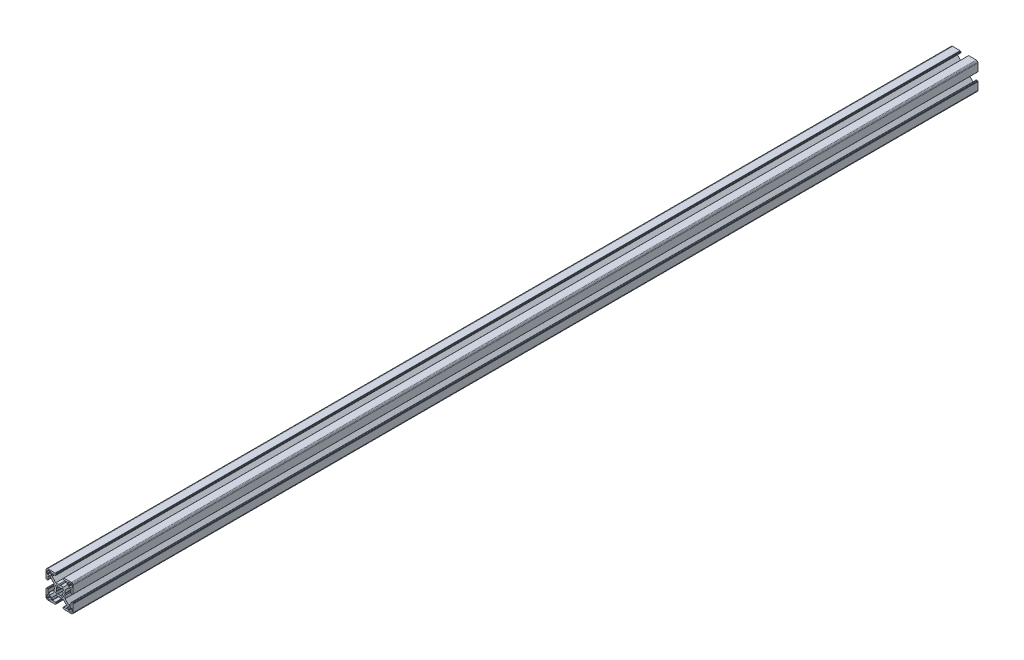
from build123d import *

# Parameters (mm, degrees)
BOSS_EXTRUDE1_DEPTH = 1000


with BuildPart() as part:
    # Sketch1 → Boss-Extrude1 (new body)
    with BuildSketch(Plane.XY):
        Polygon((28.34729664, 29.969613999), (28.000000864, 29.999999329), (19.750000909, 29.999999329), (19.715268165, 29.996961355), (19.681595266, 29.987938702), (19.649999216, 29.973205179), (19.621443003, 29.953207821), (19.596790895, 29.928557575), (19.576793537, 29.899999499), (19.562061876, 29.868405312), (19.55303736, 29.834728688), (19.549999386, 29.799999669), (19.549999386, 29.699999839), (19.546961412, 29.665268958), (19.537936896, 29.631596059), (19.523203373, 29.599998146), (19.503207877, 29.571441934), (19.478557631, 29.546789825), (19.449999556, 29.526794329), (19.418403506, 29.512060806), (19.384728745, 29.503038153), (19.349999726, 29.500000179), (19.249999896, 29.500000179), (19.215267517, 29.496958527), (19.181592755, 29.487935874), (19.149996706, 29.47320235), (19.12143863, 29.453206855), (19.096788384, 29.428554746), (19.076791026, 29.399996671), (19.062057503, 29.368402484), (19.05303485, 29.334725859), (19.049996876, 29.299998703), (19.049996876, 28.39999837), (19.059110798, 28.29580945), (19.08618062, 28.194785165), (19.13038119, 28.099997016), (19.190369539, 28.014324653), (19.264324002, 27.94037019), (19.349996366, 27.88038184), (19.444784515, 27.836181271), (19.545806937, 27.809111449), (19.650010894, 27.799984574), (23.050010706, 27.799984574), (23.084741588, 27.7969466), (23.118414487, 27.787923946), (23.150012399, 27.773190423), (23.178568612, 27.753193065), (23.203220721, 27.728542819), (23.223218079, 27.699984744), (23.237949739, 27.668386831), (23.246974255, 27.634713932), (23.25001142, 27.59998608), (23.25001142, 25.049987618), (19.204474482, 20.999982084), (15.900007876, 20.999982084), (15.000008474, 20.48483404), (14.10000814, 20.999982084), (10.795543398, 20.999982084), (7.997342887, 23.801274731), (6.750011387, 25.049984589), (6.750011387, 27.599983051), (6.753049362, 27.634713932), (6.762072946, 27.668386831), (6.776805538, 27.699984744), (6.796801965, 27.728542819), (6.821454073, 27.753193065), (6.850011218, 27.773190423), (6.881607267, 27.787923946), (6.915282029, 27.7969466), (6.950011048, 27.799984574), (10.350011791, 27.799984574), (10.45420071, 27.809098497), (10.555223133, 27.836168318), (10.650011282, 27.880368888), (10.735683645, 27.940357238), (10.809638108, 28.014311701), (10.869626458, 28.099984064), (10.913827027, 28.194772213), (10.940895918, 28.295796498), (10.950010772, 28.399985417), (10.950010772, 29.299985751), (10.946974575, 29.334739239), (10.93795065, 29.368415522), (10.923215933, 29.400009153), (10.903218427, 29.428566473), (10.878566319, 29.45321765), (10.849999264, 29.473204166), (10.818403214, 29.487937689), (10.784728453, 29.496960342), (10.749999434, 29.500000179), (10.649999604, 29.500000179), (10.615270585, 29.503038153), (10.581595823, 29.512060806), (10.549999774, 29.526794329), (10.521441698, 29.546789825), (10.496791452, 29.571441934), (10.476795025, 29.599998146), (10.462061502, 29.631596059), (10.453037918, 29.665268958), (10.449999943, 29.699999839), (10.449999943, 29.799999669), (10.446961969, 29.834728688), (10.437938385, 29.868405312), (10.423205793, 29.899999499), (10.403208435, 29.928557575), (10.378557257, 29.953207821), (10.350000113, 29.973205179), (10.318404064, 29.987938702), (10.284729302, 29.996961355), (10.250000283, 29.999999329), (1.999999397, 29.999999329), (1.652702689, 29.969613999), (1.315958682, 29.879383743), (0.999999233, 29.732050374), (0.714424066, 29.532089829), (0.467910431, 29.285576195), (0.267948955, 28.999999166), (0.120614655, 28.684040532), (0.030384399, 28.34729664), (0, 28.000000864), (0, 19.750000909), (0.003037974, 19.715268165), (0.012061559, 19.681595266), (0.026795082, 19.649999216), (0.046790577, 19.621441141), (0.071442686, 19.596789032), (0.09999983, 19.576793537), (0.13159588, 19.562060013), (0.165270641, 19.55303736), (0.19999966, 19.549999386), (0.299999461, 19.549999386), (0.334728509, 19.546959549), (0.368403242, 19.537936896), (0.399999321, 19.523203373), (0.428556465, 19.503207877), (0.453208573, 19.478555769), (0.473204069, 19.449997693), (0.487937592, 19.418403506), (0.496961176, 19.384728745), (0.499999151, 19.349999726), (0.499999151, 19.249998033), (0.503038056, 19.215269014), (0.512060709, 19.181594253), (0.526794232, 19.150000066), (0.546790194, 19.121441524), (0.571441837, 19.096789882), (0.60000029, 19.076794925), (0.631595686, 19.062061999), (0.665270619, 19.053039982), (0.700000626, 19.050000801), (1.60000096, 19.050000801), (1.704189879, 19.059116587), (1.805213233, 19.086186409), (1.90000045, 19.130385115), (1.985673745, 19.190375328), (2.059627277, 19.264327928), (2.119616325, 19.350002154), (2.163816196, 19.444788441), (2.190886018, 19.545812726), (2.200000872, 19.650001645), (2.200000872, 23.050001457), (2.203039777, 23.084732338), (2.212062431, 23.118405237), (2.226795954, 23.15000315), (2.246792381, 23.178559362), (2.271443558, 23.203211471), (2.300000702, 23.223206967), (2.331596752, 23.23794049), (2.365271513, 23.246965006), (2.400001464, 23.250001117), (4.950000857, 23.250001117), (7.997332093, 20.202670812), (8.995535423, 19.204467788), (8.995535423, 15.900001182), (9.515148227, 15.00000178), (8.995535423, 14.100002378), (8.995535423, 10.795536704), (4.950000857, 6.750002138), (2.400001464, 6.750002138), (2.365271513, 6.753040112), (2.331596752, 6.762063697), (2.300000702, 6.77679722), (2.271443558, 6.796793647), (2.246792381, 6.821444824), (2.226795954, 6.850001968), (2.212062431, 6.881598018), (2.203039777, 6.915272779), (2.200000872, 6.950002729), (2.200000872, 10.350002542), (2.190896812, 10.454174265), (2.16382699, 10.555197618), (2.119627119, 10.649984836), (2.059638071, 10.735658131), (1.985684539, 10.809611663), (1.900011244, 10.869600944), (1.805224027, 10.913800582), (1.704200673, 10.940870404), (1.600011754, 10.949986189), (0.70001142, 10.949986189), (0.665281355, 10.946948596), (0.631606253, 10.937926283), (0.600010578, 10.923193954), (0.571451747, 10.903199537), (0.546799638, 10.87854836), (0.526794232, 10.850000195), (0.512060709, 10.818404146), (0.503038056, 10.784730315), (0.499999151, 10.750000365), (0.499999151, 10.650000535), (0.496961176, 10.615270585), (0.487937592, 10.581596754), (0.473204069, 10.550000705), (0.453208573, 10.521443561), (0.428556465, 10.496791452), (0.399999321, 10.476795956), (0.368403242, 10.462062433), (0.334728509, 10.453038849), (0.299999461, 10.449999943), (0.19999966, 10.449999943), (0.165270641, 10.446961969), (0.13159588, 10.437939316), (0.09999983, 10.423205793), (0.071442686, 10.403209366), (0.046790577, 10.378558189), (0.026795082, 10.350000113), (0.012061559, 10.318404064), (0.003037974, 10.284729302), (0, 10.250000283), (0, 1.999999397), (0.030384399, 1.652702689), (0.120614655, 1.315958682), (0.267948955, 0.999999233), (0.467910431, 0.714424066), (0.714424066, 0.467910431), (0.999999233, 0.267948955), (1.315958682, 0.120614655), (1.652702689, 0.030384399), (1.999999397, 0), (10.250000283, 0), (10.284729302, 0.003037974), (10.318404064, 0.012061559), (10.350000113, 0.026795082), (10.378557257, 0.046790577), (10.403208435, 0.071442686), (10.423205793, 0.09999983), (10.437938385, 0.13159588), (10.446961969, 0.165270641), (10.449999943, 0.19999966), (10.449999943, 0.300000422), (10.453037918, 0.334729441), (10.462061502, 0.368404202), (10.476795025, 0.400000252), (10.496791452, 0.428557396), (10.521441698, 0.453208573), (10.549999774, 0.473205), (10.581595823, 0.487938523), (10.615270585, 0.496961176), (10.649999604, 0.500000082), (10.749999434, 0.500000082), (10.784728453, 0.503038056), (10.818403214, 0.512060709), (10.849999264, 0.526794232), (10.878547894, 0.546800104), (10.903198606, 0.571451747), (10.923194493, 0.6000102), (10.93792742, 0.631606528), (10.946949437, 0.66528146), (10.950010772, 0.699984975), (10.950010772, 1.599985308), (10.940895918, 1.704174228), (10.913827027, 1.805197581), (10.869626458, 1.89998573), (10.809638108, 1.985658094), (10.735683645, 2.059612557), (10.650011282, 2.119600674), (10.555223133, 2.163801476), (10.45420071, 2.190870367), (10.350011791, 2.199985221), (6.950011048, 2.199985221), (6.915282029, 2.203024126), (6.881607267, 2.212046779), (6.850011218, 2.226780302), (6.821454073, 2.246776729), (6.796801965, 2.271427907), (6.776805538, 2.299985982), (6.762072946, 2.331582032), (6.753049362, 2.365256793), (6.750011387, 2.399985812), (6.750011387, 4.949985206), (9.787457566, 7.990785077), (10.795545277, 8.999985833), (14.100010019, 8.999985833), (15.000010353, 9.515133877), (15.900009756, 8.999985833), (19.204476361, 8.999985833), (20.21256413, 7.990786065), (23.25001142, 4.949988235), (23.25001142, 2.399988841), (23.246974255, 2.365256793), (23.237949739, 2.331582032), (23.223218079, 2.299985982), (23.203220721, 2.271427907), (23.178568612, 2.246776729), (23.150012399, 2.226780302), (23.118414487, 2.212046779), (23.084741588, 2.203024126), (23.050010706, 2.199985221), (19.650010894, 2.199985221), (19.545806937, 2.190883319), (19.444784515, 2.163814428), (19.349996366, 2.119613626), (19.264324002, 2.059625509), (19.190369539, 1.985671046), (19.13038119, 1.899998682), (19.08618062, 1.805210533), (19.059110798, 1.70418718), (19.049996876, 1.599998261), (19.049996876, 0.699997927), (19.053035506, 0.665268966), (19.062058795, 0.631594374), (19.076792915, 0.599998603), (19.096790813, 0.571440905), (19.121441524, 0.546790194), (19.149999978, 0.526794306), (19.181596306, 0.51206138), (19.215271238, 0.503039363), (19.249999896, 0.500000082), (19.349999726, 0.500000082), (19.384728745, 0.496961176), (19.418403506, 0.487938523), (19.449999556, 0.473205), (19.478557631, 0.453208573), (19.503207877, 0.428557396), (19.523203373, 0.400000252), (19.537936896, 0.368404202), (19.546961412, 0.334729441), (19.549999386, 0.300000422), (19.549999386, 0.19999966), (19.55303736, 0.165270641), (19.562061876, 0.13159588), (19.576793537, 0.09999983), (19.596789964, 0.071441755), (19.621442072, 0.046789646), (19.649998285, 0.02679415), (19.681594335, 0.012060627), (19.715267234, 0.003037043), (19.750000909, 0), (28.000000864, 0), (28.34729664, 0.030384399), (28.684040532, 0.120614655), (28.999999166, 0.267948955), (29.285576195, 0.467910431), (29.532089829, 0.714424066), (29.732050374, 0.999999233), (29.879383743, 1.315958682), (29.969613999, 1.652702689), (29.999999329, 1.999999397), (29.999999329, 10.250000283), (29.996974806, 10.284715361), (29.987951516, 10.318389952), (29.973217396, 10.349985723), (29.953219499, 10.378543421), (29.928568787, 10.403194133), (29.899999499, 10.423205793), (29.868405312, 10.437939316), (29.834728688, 10.446961969), (29.799999669, 10.449999943), (29.699999839, 10.449999943), (29.664909937, 10.453400043), (29.631233313, 10.462423628), (29.599637263, 10.477157151), (29.57108105, 10.497152646), (29.546427079, 10.521804755), (29.526433446, 10.550361899), (29.511699923, 10.581957949), (29.502675407, 10.615631779), (29.499637433, 10.650361729), (29.499637433, 10.750361559), (29.49697202, 10.784715548), (29.487949367, 10.818389378), (29.473215844, 10.849985428), (29.453220348, 10.878542572), (29.428568239, 10.90319468), (29.400010164, 10.923190176), (29.368415977, 10.937923699), (29.334741215, 10.946947284), (29.300012197, 10.949986189), (28.400011863, 10.949986189), (28.29581215, 10.9408876), (28.194787865, 10.913817778), (28.099999716, 10.86961814), (28.014327352, 10.809628859), (27.940374752, 10.735675327), (27.880384539, 10.650002032), (27.836185833, 10.555214814), (27.809114148, 10.454191461), (27.800000225, 10.350002542), (27.800000225, 6.950002729), (27.796962251, 6.915272779), (27.787939598, 6.881598018), (27.773206075, 6.850001968), (27.753208716, 6.821444824), (27.728558471, 6.796793647), (27.700000395, 6.77679722), (27.668404345, 6.762063697), (27.634729584, 6.753040112), (27.599998702, 6.750002138), (25.05000024, 6.750002138), (23.809199132, 7.99080223), (21.004464477, 10.795534588), (21.004464477, 14.100000262), (20.484851673, 14.999999665), (21.004464477, 15.899999067), (21.004464477, 19.204465672), (25.05000024, 23.250001117), (27.599998702, 23.250001117), (27.634729584, 23.246965006), (27.668404345, 23.23794049), (27.700000395, 23.223206967), (27.728558471, 23.203211471), (27.753208716, 23.178559362), (27.773206075, 23.15000315), (27.787939598, 23.118405237), (27.796962251, 23.084732338), (27.800000225, 23.050001457), (27.800000225, 19.650001645), (27.809114148, 19.545812726), (27.836185833, 19.444788441), (27.880384539, 19.350002154), (27.940370508, 19.264323684), (28.014323108, 19.190371084), (28.099995472, 19.130380872), (28.194783621, 19.086182165), (28.295807906, 19.059112343), (28.400001069, 19.050000801), (29.300001402, 19.050000801), (29.334730421, 19.053040638), (29.368405183, 19.062063291), (29.39999937, 19.076796814), (29.42819671, 19.097149726), (29.452848353, 19.1218023), (29.472843309, 19.150360754), (29.487576235, 19.181955219), (29.496598252, 19.215630151), (29.499637433, 19.250359227), (29.499637433, 19.35036092), (29.502675407, 19.385089939), (29.511699923, 19.4187647), (29.526433446, 19.450358887), (29.546427079, 19.478916963), (29.57108105, 19.503569071), (29.599637263, 19.523564567), (29.631233313, 19.53829809), (29.664909937, 19.547320743), (29.699999839, 19.549999386), (29.799999669, 19.549999386), (29.834728688, 19.55303736), (29.868405312, 19.562060013), (29.899999499, 19.576793537), (29.928557575, 19.596789032), (29.953207821, 19.621441141), (29.973205179, 19.649999216), (29.987938702, 19.681595266), (29.996961355, 19.715268165), (29.999999329, 19.750000909), (29.999999329, 28.000000864), (29.969613999, 28.34729664), (29.879383743, 28.684040532), (29.732050374, 28.999999166), (29.532089829, 29.285576195), (29.285576195, 29.532089829), (28.999999166, 29.732050374), (28.684040532, 29.879383743), align=None)
        Polygon((1.299998723, 25.499999523), (1.299998723, 27.699999511), (1.312309876, 27.856435627), (1.348942518, 28.009016067), (1.408992335, 28.153989464), (1.490981318, 28.287785128), (1.592892222, 28.407108039), (1.71221327, 28.50901708), (1.846008119, 28.591006994), (1.9909814, 28.651056811), (2.143563703, 28.687689453), (2.299998887, 28.699999675), (4.499998875, 28.699999675), (4.656434059, 28.687689453), (4.809016362, 28.651056811), (4.953989759, 28.591006994), (5.087784491, 28.50901708), (5.207106471, 28.407108039), (5.309016444, 28.287785128), (5.391005427, 28.153989464), (5.451056175, 28.009016067), (5.487687886, 27.856435627), (5.499999039, 27.699999511), (5.499999039, 25.499999523), (5.487687886, 25.34356527), (5.451056175, 25.190982968), (5.391005427, 25.04600957), (5.309016444, 24.912213907), (5.207106471, 24.792892858), (5.087784491, 24.690981954), (4.953989759, 24.60899204), (4.809016362, 24.548944086), (4.656434059, 24.512309581), (4.499998875, 24.499999359), (2.299998887, 24.499999359), (2.143563703, 24.512309581), (1.9909814, 24.548944086), (1.846008119, 24.60899204), (1.71221327, 24.690981954), (1.592892222, 24.792892858), (1.490981318, 24.912213907), (1.408992335, 25.04600957), (1.348942518, 25.190982968), (1.312309876, 25.34356527), align=None, mode=Mode.SUBTRACT)
        Polygon((25.34356527, 28.687689453), (25.499999523, 28.699999675), (27.699999511, 28.699999675), (27.856435627, 28.687689453), (28.009017929, 28.651056811), (28.153991327, 28.591006994), (28.28778699, 28.50901708), (28.407108039, 28.407108039), (28.50901708, 28.287785128), (28.591006994, 28.153989464), (28.651056811, 28.009016067), (28.687689453, 27.856435627), (28.700001538, 27.699999511), (28.700001538, 25.499999523), (28.687689453, 25.34356527), (28.651056811, 25.190982968), (28.591006994, 25.04600957), (28.50901708, 24.912213907), (28.407108039, 24.792892858), (28.28778699, 24.690981954), (28.153991327, 24.60899204), (28.009017929, 24.548944086), (27.856435627, 24.512309581), (27.699999511, 24.499999359), (25.499999523, 24.499999359), (25.34356527, 24.512309581), (25.190982968, 24.548944086), (25.04600957, 24.60899204), (24.912215769, 24.690981954), (24.792892858, 24.792892858), (24.690981954, 24.912213907), (24.608993903, 25.04600957), (24.548944086, 25.190982968), (24.512311444, 25.34356527), (24.500001222, 25.499999523), (24.500001222, 27.699999511), (24.512311444, 27.856435627), (24.548944086, 28.009016067), (24.608993903, 28.153989464), (24.690981954, 28.287785128), (24.792892858, 28.407108039), (24.912215769, 28.50901708), (25.04600957, 28.591006994), (25.190982968, 28.651056811), align=None, mode=Mode.SUBTRACT)
        Polygon((14.999999665, 18.649999052), (15.550030395, 18.608318642), (16.087498516, 18.484227359), (16.600128263, 18.280562013), (18.13592948, 19.518401474), (18.644984812, 19.11874488), (19.103571773, 18.662061542), (19.505336881, 18.154669553), (18.280562013, 16.600130126), (18.484227359, 16.087498516), (18.608318642, 15.550030395), (18.649999052, 14.999999665), (18.608318642, 14.449968934), (18.484227359, 13.912500814), (18.280562013, 13.399870135), (19.505336881, 11.845329776), (19.103571773, 11.337937787), (18.644984812, 10.881252587), (18.13592948, 10.481598787), (16.600128263, 11.719437316), (16.087498516, 11.515771039), (15.550030395, 11.391680688), (14.999999665, 11.349999346), (14.449968934, 11.391680688), (13.912500814, 11.515771039), (13.399870135, 11.719437316), (11.864069849, 10.481598787), (11.355013587, 10.881252587), (10.896427557, 11.337937787), (10.494662449, 11.845329776), (11.719438247, 13.399870135), (11.515771039, 13.912500814), (11.391680688, 14.449968934), (11.349999346, 14.999999665), (11.391680688, 15.550030395), (11.515771039, 16.087498516), (11.719438247, 16.600130126), (10.494662449, 18.154669553), (10.896427557, 18.662061542), (11.355013587, 19.11874488), (11.864069849, 19.518401474), (13.399870135, 18.280562013), (13.912500814, 18.484227359), (14.449968934, 18.608318642), align=None, mode=Mode.SUBTRACT)
        Polygon((4.499998875, 1.299999771), (2.299998887, 1.299999771), (2.143563703, 1.312310807), (1.9909814, 1.348942518), (1.846008119, 1.408992335), (1.71221327, 1.490982249), (1.592892222, 1.592892222), (1.490981318, 1.712214202), (1.408992335, 1.846008934), (1.348942518, 1.990982331), (1.312309876, 2.143564634), (1.299998723, 2.299998887), (1.299998723, 4.499999806), (1.312309876, 4.656434059), (1.348942518, 4.809017293), (1.408992335, 4.95399069), (1.490981318, 5.087785423), (1.592892222, 5.207106471), (1.71221327, 5.309017375), (1.846008119, 5.391006358), (1.9909814, 5.451056175), (2.143563703, 5.487688817), (2.299998887, 5.49999997), (4.499998875, 5.49999997), (4.656434059, 5.487688817), (4.809016362, 5.451056175), (4.953989759, 5.391006358), (5.087784491, 5.309017375), (5.207106471, 5.207106471), (5.309016444, 5.087785423), (5.391005427, 4.95399069), (5.451056175, 4.809017293), (5.487687886, 4.656434059), (5.499999039, 4.499999806), (5.499999039, 2.299998887), (5.487687886, 2.143564634), (5.451056175, 1.990982331), (5.391005427, 1.846008934), (5.309016444, 1.712214202), (5.207106471, 1.592892222), (5.087784491, 1.490982249), (4.953989759, 1.408992335), (4.809016362, 1.348942518), (4.656434059, 1.312310807), align=None, mode=Mode.SUBTRACT)
        Polygon((27.699999511, 1.299999771), (25.499999523, 1.299999771), (25.34356527, 1.312310807), (25.190982968, 1.348942518), (25.04600957, 1.408992335), (24.912215769, 1.490982249), (24.792892858, 1.592892222), (24.690981954, 1.712214202), (24.608993903, 1.846008934), (24.548944086, 1.990982331), (24.512311444, 2.143564634), (24.500001222, 2.299998887), (24.500001222, 4.499999806), (24.512311444, 4.656434059), (24.548944086, 4.809017293), (24.608993903, 4.95399069), (24.690981954, 5.087785423), (24.792892858, 5.207106471), (24.912215769, 5.309017375), (25.04600957, 5.391006358), (25.190982968, 5.451056175), (25.34356527, 5.487688817), (25.499999523, 5.49999997), (27.699999511, 5.49999997), (27.856435627, 5.487688817), (28.009017929, 5.451056175), (28.153991327, 5.391006358), (28.28778699, 5.309017375), (28.407108039, 5.207106471), (28.50901708, 5.087785423), (28.591006994, 4.95399069), (28.651056811, 4.809017293), (28.687689453, 4.656434059), (28.700001538, 4.499999806), (28.700001538, 2.299998887), (28.687689453, 2.143564634), (28.651056811, 1.990982331), (28.591006994, 1.846008934), (28.50901708, 1.712214202), (28.407108039, 1.592892222), (28.28778699, 1.490982249), (28.153991327, 1.408992335), (28.009017929, 1.348942518), (27.856435627, 1.312310807), align=None, mode=Mode.SUBTRACT)
    extrude(amount=-BOSS_EXTRUDE1_DEPTH)


solid = part.part
